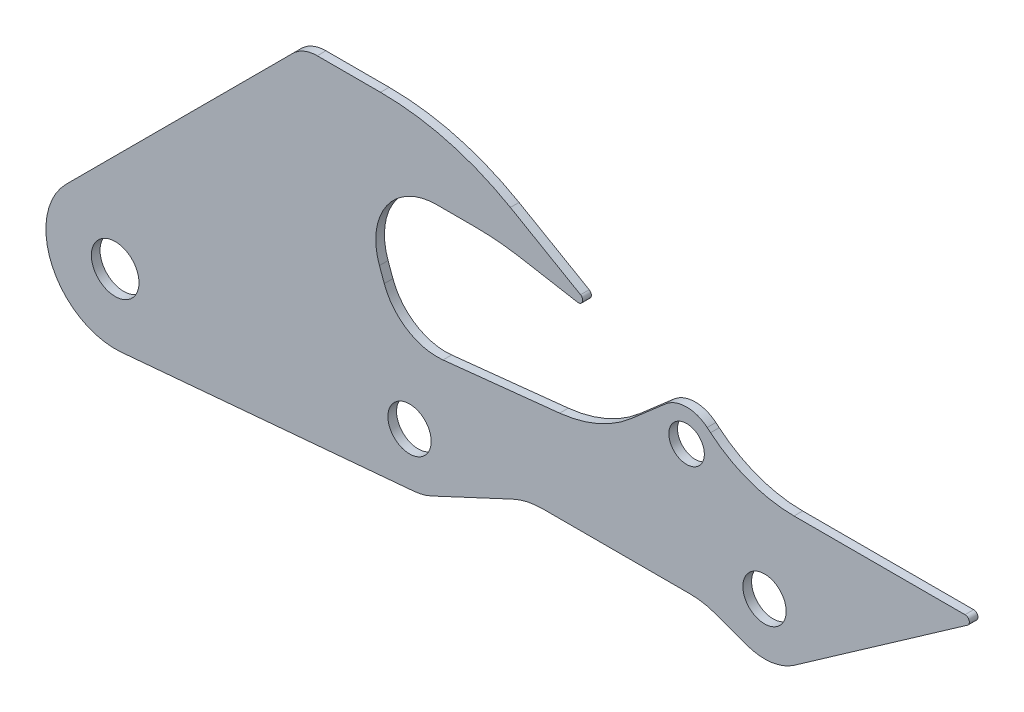
from build123d import *

# Parameters (mm, degrees)
SKETCH1_R          = 27.5
SKETCH1_R_2        = 25
SKETCH1_R_3        = 20.5
BASE_EXTRUDE_DEPTH = 10


with BuildPart() as part:
    # Sketch1 → Base-Extrude (new body)
    with BuildSketch(Plane.XY):
        with BuildLine():
            Line((7.049670091, -79.688783098), (345.287252568, -49.766587323))
            ThreePointArc((345.287252568, -49.766587323), (355.557216326, -47.948019985), (365.357095704, -44.378467222))
            Line((365.357095704, -44.378467222), (459.062839102, -0.682761463))
            ThreePointArc((459.062839102, -0.682761463), (475.969488221, 5.056272584), (493.717536564, 7))
            Line((493.717536564, 7), (664.517065511, 7))
            ThreePointArc((664.517065511, 7), (678.75621608, 5.754235747), (692.562717264, 2.054794904))
            Line((692.562717264, 2.054794904), (729.4787914, -11.381557247))
            ThreePointArc((729.4787914, -11.381557247), (757.831571533, -14.486691682), (784.414586181, -4.149122657))
            Line((784.414586181, -4.149122657), (984.431516581, 135.904239779))
            ThreePointArc((984.431516581, 135.904239779), (986.332219153, 141.503528998), (981.5636344, 145))
            Line((981.5636344, 145), (784.07485266, 145))
            ThreePointArc((784.07485266, 145), (732.771831161, 154.046106882), (687.656711207, 180.093333532))
            Line((687.656711207, 180.093333532), (683.783141558, 183.343644395))
            ThreePointArc((683.783141558, 183.343644395), (659.677118187, 191.998591153), (635.725815927, 182.924254468))
            Line((635.725815927, 182.924254468), (596.111500497, 148.488055437))
            ThreePointArc((596.111500497, 148.488055437), (557.515006487, 124.135481312), (513.381915638, 112.516208165))
            Line((513.381915638, 112.516208165), (378.657265123, 98.356076801))
            ThreePointArc((378.657265123, 98.356076801), (337.418162835, 107.87687375), (310.782894659, 140.768690684))
            Line((310.782894659, 140.768690684), (305.217826435, 156.058589967))
            ThreePointArc((305.217826435, 156.058589967), (313.65566679, 220.150350545), (370.99630989, 250))
            Line((370.99630989, 250), (415.871293046, 250))
            ThreePointArc((415.871293046, 250), (442.01801587, 248.858409428), (467.965746346, 245.442325904))
            Line((467.965746346, 245.442325904), (534.131759112, 233.775472647))
            ThreePointArc((534.131759112, 233.775472647), (539.698463104, 236.989410696), (537.5, 243.029638431))
            Line((537.5, 243.029638431), (456.478157281, 289.807621135))
            ThreePointArc((456.478157281, 289.807621135), (384.123870812, 319.777747887), (306.478157281, 330))
            Line((306.478157281, 330), (233.431457505, 330))
            ThreePointArc((233.431457505, 330), (218.12412021, 326.9551813), (205.147186258, 318.284271247))
            Line((205.147186258, 318.284271247), (-56.568542495, 56.568542495))
            ThreePointArc((-56.568542495, 56.568542495), (-72.488236118, -33.844580431), (7.049670091, -79.688783098))
        make_face()
        Circle(SKETCH1_R, mode=Mode.SUBTRACT)
        with Locations((340, 10)):
            Circle(SKETCH1_R_2, mode=Mode.SUBTRACT)
        with Locations((750, 45)):
            Circle(SKETCH1_R_2, mode=Mode.SUBTRACT)
        with Locations((660, 155)):
            Circle(SKETCH1_R_3, mode=Mode.SUBTRACT)
    extrude(amount=-BASE_EXTRUDE_DEPTH)


solid = part.part
